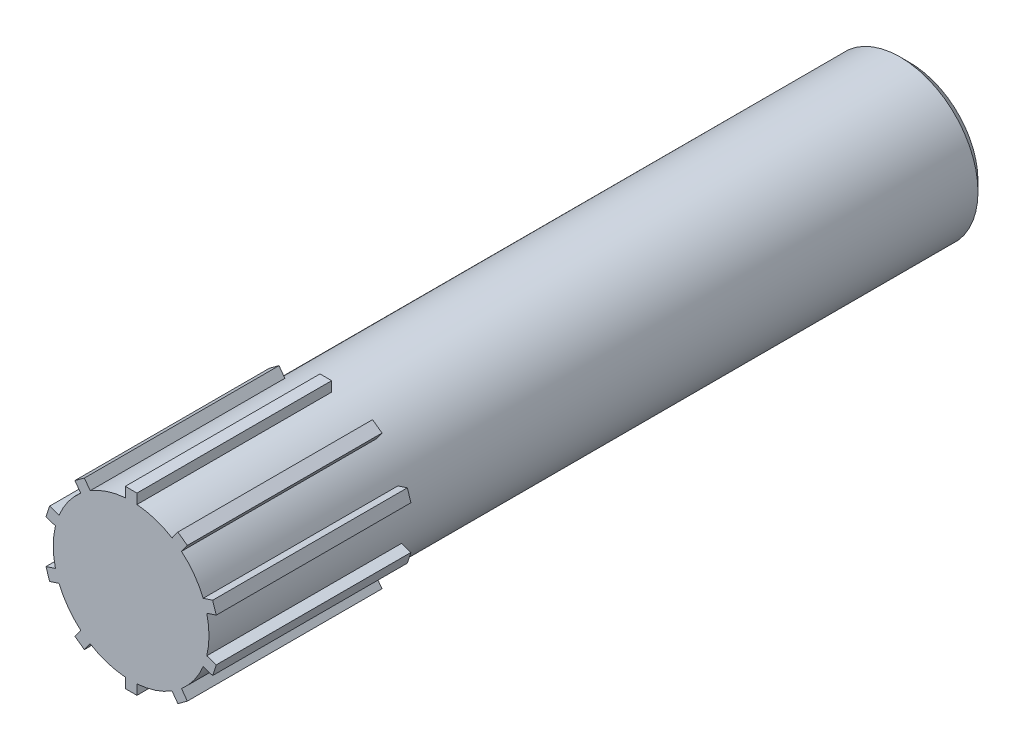
from build123d import *

# Parameters (mm, degrees)
SKETCH1_R           = 4
BOSS_EXTRUDE1_DEPTH = 40
CUT_EXTRUDE1_START  = -2.5
CUT_EXTRUDE1_DEPTH  = 2.5
SKETCH3_W           = 0.6
SKETCH3_H           = 2.558346845
BOSS_EXTRUDE2_DEPTH = 10
CIRPATTERN1_COUNT   = 10
CHAMFER1_SIZE       = 0.5


with BuildPart() as part:
    # Sketch1 → Boss-Extrude1 (new body)
    with BuildSketch(Plane.XY):
        Circle(SKETCH1_R)
    extrude(amount=BOSS_EXTRUDE1_DEPTH)

    # Sketch2 → Cut-Extrude1 (cut, through all)
    with BuildSketch(Plane(origin=(0, 0, 0), x_dir=(1, 0, 0), z_dir=(0, 1, 0)).offset(CUT_EXTRUDE1_START)):
        with BuildLine():
            Line((1.5, -5), (1.5, -9))
            ThreePointArc((1.5, -9), (0, -10.5), (-1.5, -9))
            Line((-1.5, -9), (-1.5, -5))
            ThreePointArc((-1.5, -5), (0, -3.5), (1.5, -5))
        make_face()
    extrude(amount=-CUT_EXTRUDE1_DEPTH, mode=Mode.SUBTRACT)

    # Sketch3 → Boss-Extrude2 (add)
    with BuildSketch(Plane.XY.offset(40)):
        with Locations((0, 3.220826578)):
            Rectangle(SKETCH3_W, SKETCH3_H)
    boss_extrude2 = extrude(amount=-BOSS_EXTRUDE2_DEPTH)

    # CirPattern1: Boss-Extrude2 ×10 about axis
    cirpattern1_axis = Axis((0, 0, 0), (0, 0, 1))
    for i in range(1, CIRPATTERN1_COUNT):
        add(boss_extrude2.rotate(cirpattern1_axis, i * 360 / CIRPATTERN1_COUNT))

    # Chamfer1
    chamfer1_edges = [part.edges().sort_by_distance(p)[0] for p in [
        (-4, 0, 0),
    ]]
    chamfer(chamfer1_edges, length=CHAMFER1_SIZE)


solid = part.part
